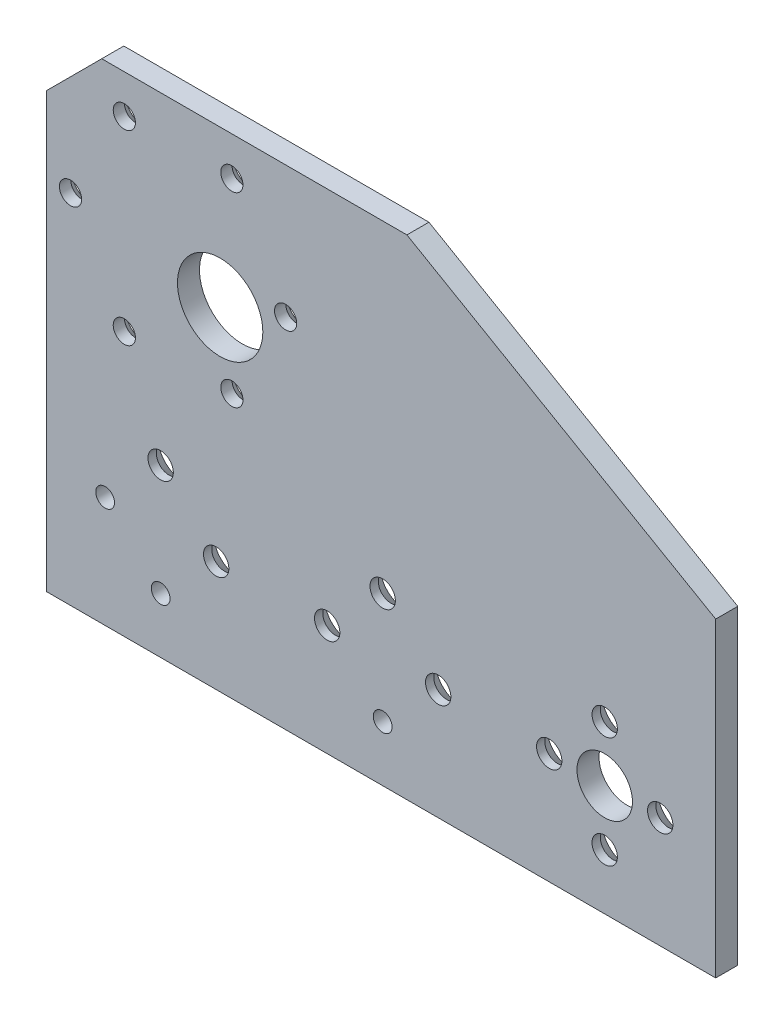
from build123d import *

# Parameters (mm, degrees)
SKETCH1_R                                       = 4
BOSS_EXTRUDE1_DEPTH                             = 3.175
F_31_64_0_48438_DIAMETER_HOLE1_D                = 12.303252
F_6_32_TAPPED_HOLE1_D                           = 2.7051
CSK_FOR_M3_FLAT_HEAD_MACHINE_SCREW2_D           = 3.2
CSK_FOR_M3_FLAT_HEAD_MACHINE_SCREW2_CSINK_D     = 6.3
CSK_FOR_M3_FLAT_HEAD_MACHINE_SCREW2_CSINK_ANGLE = 90
CSK_FOR_6_FLAT_HEAD_MACHINE_SCREW3_AT_2_COUNT   = 2
CSK_FOR_6_FLAT_HEAD_MACHINE_SCREW3_AT_2_PITCH   = 11.313708499
CSK_FOR_6_FLAT_HEAD_MACHINE_SCREW3_AT_3_COUNT   = 2
CSK_FOR_6_FLAT_HEAD_MACHINE_SCREW3_AT_3_PITCH   = 11.313708499
CSK_FOR_6_FLAT_HEAD_MACHINE_SCREW3_AT_4_COUNT   = 2
CSK_FOR_6_FLAT_HEAD_MACHINE_SCREW3_AT_4_PITCH   = 16
CSK_FOR_6_FLAT_HEAD_MACHINE_SCREW3_AT_5_COUNT   = 2
CSK_FOR_6_FLAT_HEAD_MACHINE_SCREW3_AT_5_PITCH   = 25.298221281
CSK_FOR_6_FLAT_HEAD_MACHINE_SCREW3_AT_6_COUNT   = 2
CSK_FOR_6_FLAT_HEAD_MACHINE_SCREW3_AT_6_PITCH   = 32
CSK_FOR_6_FLAT_HEAD_MACHINE_SCREW3_AT_7_COUNT   = 2
CSK_FOR_6_FLAT_HEAD_MACHINE_SCREW3_AT_7_PITCH   = 40.792156109
CSK_FOR_6_FLAT_HEAD_MACHINE_SCREW3_AT_8_COUNT   = 2
CSK_FOR_6_FLAT_HEAD_MACHINE_SCREW3_AT_8_PITCH   = 56.568542495
CSK_FOR_6_FLAT_HEAD_MACHINE_SCREW3_AT_9_COUNT   = 2
CSK_FOR_6_FLAT_HEAD_MACHINE_SCREW3_AT_9_PITCH   = 64


with BuildPart() as part:
    # Sketch1 → Boss-Extrude1 (new body)
    with BuildSketch(Plane.XY):
        Polygon((16, -16), (-80.487803669, -16), (-80.487803669, 46.5), (-72.487803669, 54.5), (-28.507138544, 54.5), (16, 28.803791581), align=None)
        Circle(SKETCH1_R, mode=Mode.SUBTRACT)
    extrude(amount=-BOSS_EXTRUDE1_DEPTH)

    # 31_64 _0.48438_ Diameter Hole1 (through all)
    with Locations(Plane.XY):
        with Locations((-55.425625842, 32)):
            Hole(F_31_64_0_48438_DIAMETER_HOLE1_D / 2)

    # 6-32 Tapped Hole1 (through all)
    with Locations(Plane.XY):
        with Locations((-72, 0), (-32, -8), (-64, -8)):
            Hole(F_6_32_TAPPED_HOLE1_D / 2)

    # CSK for M3 Flat Head Machine Screw2 (through all)
    with Locations(Plane(origin=(0, 0, -3.175), x_dir=(-1, 0, 0), z_dir=(0, 0, -1))):
        with Locations((69.237803669, 48.923393759), (53.737803669, 48.923393759), (45.987803669, 35.5), (53.737803669, 22.076606241), (69.237803669, 22.076606241), (76.987803669, 35.5)):
            CounterSinkHole(CSK_FOR_M3_FLAT_HEAD_MACHINE_SCREW2_D / 2, CSK_FOR_M3_FLAT_HEAD_MACHINE_SCREW2_CSINK_D / 2, counter_sink_angle=CSK_FOR_M3_FLAT_HEAD_MACHINE_SCREW2_CSINK_ANGLE)

    # Sketch17 → CSK for _6 Flat Head Machine Screw3 (revolve, cut)
    with BuildSketch(Plane(origin=(0, 8, -3.175), x_dir=(0, 1, 0), z_dir=(1, 0, 0))):
        Polygon((0, 0), (0, 3.175), (1.8288, 3.175), (1.8288, 1.972306634), (3.5433, 0), align=None)
    csk_for_6_flat_head_machine_screw3 = revolve(axis=Axis((0, 8, -9.525), (0, 0, 1)), mode=Mode.SUBTRACT)

    # CSK for _6 Flat Head Machine Screw3 at 2: CSK for _6 Flat Head Machine Screw3 ×2
    with Locations(*[Vector(0.707106781, -0.707106781, 0) * (i * CSK_FOR_6_FLAT_HEAD_MACHINE_SCREW3_AT_2_PITCH) for i in range(1, CSK_FOR_6_FLAT_HEAD_MACHINE_SCREW3_AT_2_COUNT)]):
        add(csk_for_6_flat_head_machine_screw3, mode=Mode.SUBTRACT)

    # CSK for _6 Flat Head Machine Screw3 at 3: CSK for _6 Flat Head Machine Screw3 ×2
    with Locations(*[Vector(-0.707106781, -0.707106781, 0) * (i * CSK_FOR_6_FLAT_HEAD_MACHINE_SCREW3_AT_3_PITCH) for i in range(1, CSK_FOR_6_FLAT_HEAD_MACHINE_SCREW3_AT_3_COUNT)]):
        add(csk_for_6_flat_head_machine_screw3, mode=Mode.SUBTRACT)

    # CSK for _6 Flat Head Machine Screw3 at 4: CSK for _6 Flat Head Machine Screw3 ×2
    with Locations(*[(0, -i * CSK_FOR_6_FLAT_HEAD_MACHINE_SCREW3_AT_4_PITCH, 0) for i in range(1, CSK_FOR_6_FLAT_HEAD_MACHINE_SCREW3_AT_4_COUNT)]):
        add(csk_for_6_flat_head_machine_screw3, mode=Mode.SUBTRACT)

    # CSK for _6 Flat Head Machine Screw3 at 5: CSK for _6 Flat Head Machine Screw3 ×2
    with Locations(*[Vector(-0.948683298, -0.316227766, 0) * (i * CSK_FOR_6_FLAT_HEAD_MACHINE_SCREW3_AT_5_PITCH) for i in range(1, CSK_FOR_6_FLAT_HEAD_MACHINE_SCREW3_AT_5_COUNT)]):
        add(csk_for_6_flat_head_machine_screw3, mode=Mode.SUBTRACT)

    # CSK for _6 Flat Head Machine Screw3 at 6: CSK for _6 Flat Head Machine Screw3 ×2
    with Locations(*[(-i * CSK_FOR_6_FLAT_HEAD_MACHINE_SCREW3_AT_6_PITCH, 0, 0) for i in range(1, CSK_FOR_6_FLAT_HEAD_MACHINE_SCREW3_AT_6_COUNT)]):
        add(csk_for_6_flat_head_machine_screw3, mode=Mode.SUBTRACT)

    # CSK for _6 Flat Head Machine Screw3 at 7: CSK for _6 Flat Head Machine Screw3 ×2
    with Locations(*[Vector(-0.980580676, -0.196116135, 0) * (i * CSK_FOR_6_FLAT_HEAD_MACHINE_SCREW3_AT_7_PITCH) for i in range(1, CSK_FOR_6_FLAT_HEAD_MACHINE_SCREW3_AT_7_COUNT)]):
        add(csk_for_6_flat_head_machine_screw3, mode=Mode.SUBTRACT)

    # CSK for _6 Flat Head Machine Screw3 at 8: CSK for _6 Flat Head Machine Screw3 ×2
    with Locations(*[Vector(-0.989949494, -0.141421356, 0) * (i * CSK_FOR_6_FLAT_HEAD_MACHINE_SCREW3_AT_8_PITCH) for i in range(1, CSK_FOR_6_FLAT_HEAD_MACHINE_SCREW3_AT_8_COUNT)]):
        add(csk_for_6_flat_head_machine_screw3, mode=Mode.SUBTRACT)

    # CSK for _6 Flat Head Machine Screw3 at 9: CSK for _6 Flat Head Machine Screw3 ×2
    with Locations(*[(-i * CSK_FOR_6_FLAT_HEAD_MACHINE_SCREW3_AT_9_PITCH, 0, 0) for i in range(1, CSK_FOR_6_FLAT_HEAD_MACHINE_SCREW3_AT_9_COUNT)]):
        add(csk_for_6_flat_head_machine_screw3, mode=Mode.SUBTRACT)


solid = part.part
